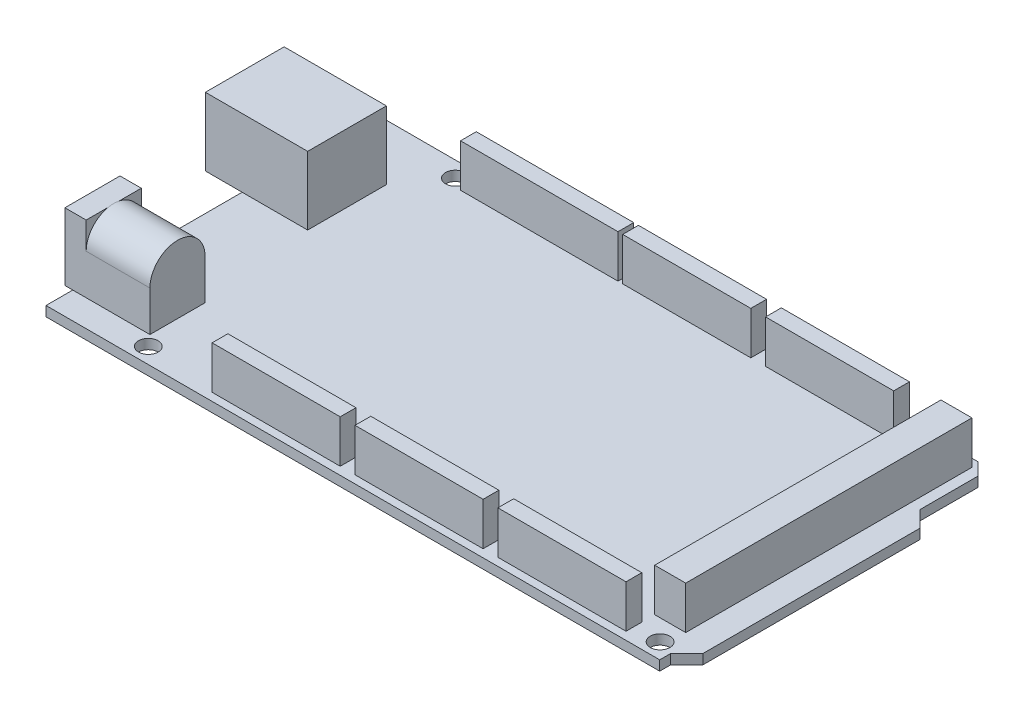
from build123d import *

# Parameters (mm, degrees)
SKETCH1_R           = 1.5875
BOSS_EXTRUDE1_DEPTH = 1.5875
BOSS_EXTRUDE2_START = 1.5875
SKETCH1_3_W         = 5.9309
SKETCH1_3_H         = 12.7
SKETCH1_3_W_2       = 10.5691
BOSS_EXTRUDE2_DEPTH = 11
BOSS_EXTRUDE3_START = 1.5875
SKETCH1_4_W         = 10.286
SKETCH1_4_H         = 8.89
BOSS_EXTRUDE3_DEPTH = 6.5
BOSS_EXTRUDE4_START = 1.5875
SKETCH1_5_W         = 1.27
SKETCH1_5_H         = 8.89
SKETCH1_5_W_2       = 2.16
BOSS_EXTRUDE4_DEPTH = 10.86
SKETCH2_W           = 10.286
SKETCH2_H           = 4.445
REVOLVE1_ANGLE      = 180
SKETCH1_6_W         = 20.6629
SKETCH1_6_H         = 2.54
SKETCH1_6_W_2       = 5
SKETCH1_6_H_2       = 46.17
SKETCH1_6_W_3       = 25.4
BOSS_EXTRUDE5_DEPTH = 8.5


with BuildPart() as part:
    # Sketch1 → Boss-Extrude1 (new body)
    with BuildSketch(Plane(origin=(0, 0, 0), x_dir=(1, 0, 0), z_dir=(0, 1, 0))):
        Polygon((0, 0), (0, 53.34), (97, 53.34), (99, 51.34), (99, 41.95), (101.6, 39.35), (101.6, 4.35), (99, 1.75), (99, 0), align=None)
        with Locations((96.52, 2.54)):
            Circle(SKETCH1_R, mode=Mode.SUBTRACT)
        with Locations((71.074776633, 7.62)):
            Circle(SKETCH1_R, mode=Mode.SUBTRACT)
        with Locations((13.97, 2.54)):
            Circle(SKETCH1_R, mode=Mode.SUBTRACT)
        with Locations((15.24, 50.8)):
            Circle(SKETCH1_R, mode=Mode.SUBTRACT)
        with Locations((90.17, 50.8)):
            Circle(SKETCH1_R, mode=Mode.SUBTRACT)
    extrude(amount=BOSS_EXTRUDE1_DEPTH)

    # Sketch1_3 → Boss-Extrude2 (add)
    with BuildSketch(Plane(origin=(0, 0, 0), x_dir=(1, 0, 0), z_dir=(0, 1, 0)).offset(BOSS_EXTRUDE2_START)):
        with Locations((-2.96545, 37.99)):
            Rectangle(SKETCH1_3_W, SKETCH1_3_H)
        with Locations((5.28455, 37.99)):
            Rectangle(SKETCH1_3_W_2, SKETCH1_3_H)
    extrude(amount=BOSS_EXTRUDE2_DEPTH)

    # Sketch1_4 → Boss-Extrude3 (add)
    with BuildSketch(Plane(origin=(0, 0, 0), x_dir=(1, 0, 0), z_dir=(0, 1, 0)).offset(BOSS_EXTRUDE3_START)):
        with Locations((7.303, 8.763)):
            Rectangle(SKETCH1_4_W, SKETCH1_4_H)
    extrude(amount=BOSS_EXTRUDE3_DEPTH)

    # Sketch1_5 → Boss-Extrude4 (add)
    with BuildSketch(Plane(origin=(0, 0, 0), x_dir=(1, 0, 0), z_dir=(0, 1, 0)).offset(BOSS_EXTRUDE4_START)):
        with Locations((-0.635, 8.763)):
            Rectangle(SKETCH1_5_W, SKETCH1_5_H)
        with Locations((1.08, 8.763)):
            Rectangle(SKETCH1_5_W_2, SKETCH1_5_H)
    extrude(amount=BOSS_EXTRUDE4_DEPTH)

    # Sketch2 → Revolve1 (revolve)
    with BuildSketch(Plane(origin=(0, 8.0875, 0), x_dir=(1, 0, 0), z_dir=(0, 1, 0))):
        with Locations((7.303, 6.5405)):
            Rectangle(SKETCH2_W, SKETCH2_H)
    revolve(axis=Axis((2.16, 8.0875, -8.763), (-1, 0, 0)), revolution_arc=REVOLVE1_ANGLE)

    # Sketch1_6 → Boss-Extrude5 (add)
    with BuildSketch(Plane(origin=(0, 0, 0), x_dir=(1, 0, 0), z_dir=(0, 1, 0))):
        with Locations((58.90895, 2.54)):
            Rectangle(SKETCH1_6_W, SKETCH1_6_H)
        with Locations((81.95945, 2.54)):
            Rectangle(SKETCH1_6_W, SKETCH1_6_H)
        with Locations((94.7909, 28.985)):
            Rectangle(SKETCH1_6_W_2, SKETCH1_6_H_2)
        with Locations((35.85845, 2.54)):
            Rectangle(SKETCH1_6_W, SKETCH1_6_H)
        with Locations((76.87945, 50.8)):
            Rectangle(SKETCH1_6_W, SKETCH1_6_H)
        with Locations((53.82895, 50.8)):
            Rectangle(SKETCH1_6_W, SKETCH1_6_H)
        with Locations((30.0355, 50.8)):
            Rectangle(SKETCH1_6_W_3, SKETCH1_6_H)
    extrude(amount=BOSS_EXTRUDE5_DEPTH)


solid = part.part
